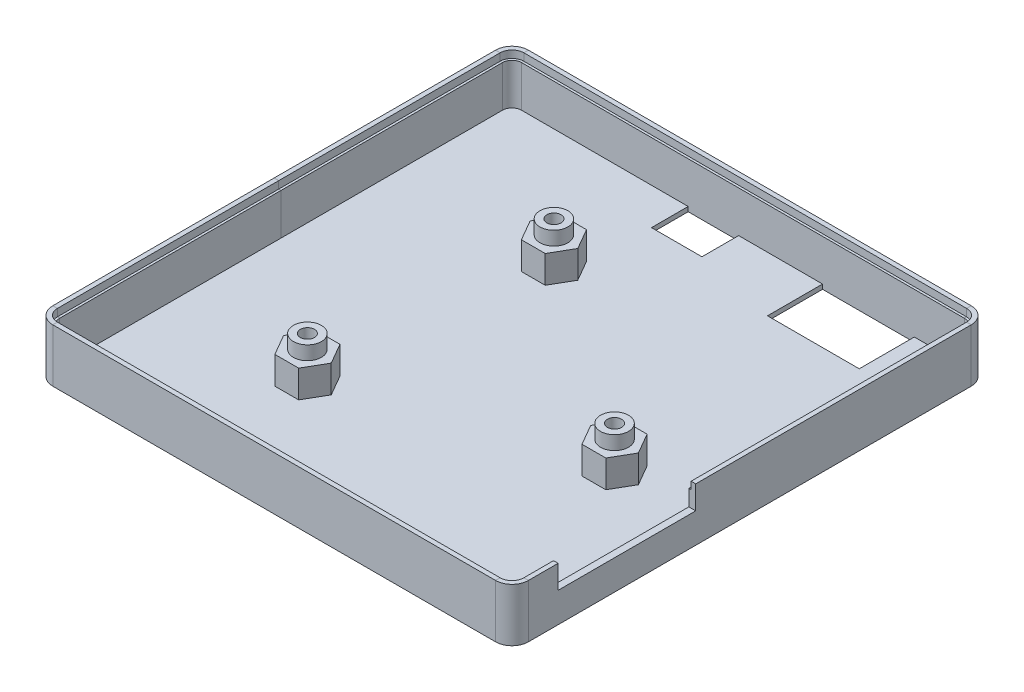
from build123d import *

# Parameters (mm, degrees)
SKETCH5_R           = 1.55
BOSS_EXTRUDE2_DEPTH = 1
BOSS_EXTRUDE3_START = -3
SKETCH6_R           = 1.55
BOSS_EXTRUDE3_DEPTH = 6
SKETCH11_R          = 3.05
SKETCH11_R_2        = 1.55
BOSS_EXTRUDE4_DEPTH = 3
CUT_EXTRUDE1_START  = 2
CUT_EXTRUDE1_DEPTH  = 6
SKETCH8_W           = 11
SKETCH8_H           = 8
SKETCH8_W_2         = 20
SKETCH8_H_2         = 12
CUT_EXTRUDE2_DEPTH  = 2
SKETCH9_W           = 0.45
SKETCH9_H           = 30
CUT_EXTRUDE3_DEPTH  = 3.5
CUT_EXTRUDE4_REACH  = 105.7
SKETCH10_W          = 30
SKETCH10_H          = 5.1


with BuildPart() as part:
    # Sweep1: sweep along a path in Sketch1
    with BuildLine(Plane(origin=(0, 0, 0), x_dir=(1, 0, 0), z_dir=(0, 1, 0))) as sweep1_path:
        Line((-48.26, -50.8), (48.26, -50.8))
        ThreePointArc((48.26, -50.8), (50.056051224, -50.056051224), (50.8, -48.26))
        Line((50.8, -48.26), (50.8, 48.26))
        ThreePointArc((50.8, 48.26), (50.056051224, 50.056051224), (48.26, 50.8))
        Line((48.26, 50.8), (-48.26, 50.8))
        ThreePointArc((-48.26, 50.8), (-50.056051224, 50.056051224), (-50.8, 48.26))
        Line((-50.8, 48.26), (-50.8, -48.26))
        ThreePointArc((-50.8, -48.26), (-50.056051224, -50.056051224), (-48.26, -50.8))
    # Sketch3 → Sweep1 (sweep)
    with BuildSketch(Plane.XY):
        Polygon((-50.85, 1.6), (-51.85, 1.6), (-51.85, -10), (-50.35, -10), (-50.35, 0), (-50.85, 0), align=None)
    sweep(path=sweep1_path.line)

    # Sketch5 → Boss-Extrude2 (add)
    with BuildSketch(Plane.XZ.offset(10)):
        with BuildLine():
            Line((-50.8, 48.26), (-50.8, -48.26))
            ThreePointArc((-50.8, -48.26), (-50.056051224, -50.056051224), (-48.26, -50.8))
            Line((-48.26, -50.8), (48.26, -50.8))
            ThreePointArc((48.26, -50.8), (50.056051224, -50.056051224), (50.8, -48.26))
            Line((50.8, -48.26), (50.8, 48.26))
            ThreePointArc((50.8, 48.26), (50.056051224, 50.056051224), (48.26, 50.8))
            Line((48.26, 50.8), (-48.26, 50.8))
            ThreePointArc((-48.26, 50.8), (-50.056051224, 50.056051224), (-50.8, 48.26))
        make_face()
        with Locations((-15.24, -24.384)):
            Circle(SKETCH5_R, mode=Mode.SUBTRACT)
        with Locations((29.972, 7.62)):
            Circle(SKETCH5_R, mode=Mode.SUBTRACT)
        with Locations((-20.4724, 24.13)):
            Circle(SKETCH5_R, mode=Mode.SUBTRACT)
    extrude(amount=-BOSS_EXTRUDE2_DEPTH)

    # Sketch6 → Boss-Extrude3 (add)
    with BuildSketch(Plane(origin=(0, 0, 0), x_dir=(1, 0, 0), z_dir=(0, 1, 0)).offset(BOSS_EXTRUDE3_START)):
        Polygon((-10.043847577, 24.384), (-12.641923789, 28.884), (-17.838076211, 28.884), (-20.436152423, 24.384), (-17.838076211, 19.884), (-12.641923789, 19.884), align=None)
        with Locations((-15.24, 24.384)):
            Circle(SKETCH6_R, mode=Mode.SUBTRACT)
        Polygon((35.168152423, -7.62), (32.570076211, -3.12), (27.373923789, -3.12), (24.775847577, -7.62), (27.373923789, -12.12), (32.570076211, -12.12), align=None)
        with Locations((29.972, -7.62)):
            Circle(SKETCH6_R, mode=Mode.SUBTRACT)
        Polygon((-15.276247577, -24.13), (-17.874323789, -19.63), (-23.070476211, -19.63), (-25.668552423, -24.13), (-23.070476211, -28.63), (-17.874323789, -28.63), align=None)
        with Locations((-20.4724, -24.13)):
            Circle(SKETCH6_R, mode=Mode.SUBTRACT)
    extrude(amount=-BOSS_EXTRUDE3_DEPTH)

    # Sketch11 → Boss-Extrude4 (add)
    with BuildSketch(Plane(origin=(0, -3, 0), x_dir=(1, 0, 0), z_dir=(0, 1, 0))):
        with Locations((-15.24, 24.384)):
            Circle(SKETCH11_R)
        with Locations((-15.24, 24.384)):
            Circle(SKETCH11_R_2, mode=Mode.SUBTRACT)
        with Locations((-20.4724, -24.13)):
            Circle(SKETCH11_R)
        with Locations((-20.4724, -24.13)):
            Circle(SKETCH11_R_2, mode=Mode.SUBTRACT)
        with Locations((29.972, -7.62)):
            Circle(SKETCH11_R)
        with Locations((29.972, -7.62)):
            Circle(SKETCH11_R_2, mode=Mode.SUBTRACT)
    extrude(amount=BOSS_EXTRUDE4_DEPTH)

    # Sketch7 → Cut-Extrude1 (cut, through all)
    with BuildSketch(Plane.XZ.offset(3).offset(CUT_EXTRUDE1_START)):
        Polygon((-17.239238493, 24.13), (-18.855819246, 26.93), (-22.088980754, 26.93), (-23.705561507, 24.13), (-22.088980754, 21.33), (-18.855819246, 21.33), align=None)
        Polygon((33.205161507, 7.62), (31.588580754, 10.42), (28.355419246, 10.42), (26.738838493, 7.62), (28.355419246, 4.82), (31.588580754, 4.82), align=None)
        Polygon((-12.006838493, -24.384), (-13.623419246, -21.584), (-16.856580754, -21.584), (-18.473161507, -24.384), (-16.856580754, -27.184), (-13.623419246, -27.184), align=None)
    extrude(amount=CUT_EXTRUDE1_DEPTH, mode=Mode.SUBTRACT)

    # Sketch8 → Cut-Extrude2 (cut, through all)
    with BuildSketch(Plane(origin=(0, -9, 0), x_dir=(1, 0, 0), z_dir=(0, 1, 0))):
        with Locations((-6.4408, 46.35)):
            Rectangle(SKETCH8_W, SKETCH8_H)
        with BuildLine():
            Line((50.35, -41.35), (50.35, -48.26))
            ThreePointArc((50.35, -48.26), (49.737853173, -49.737853173), (48.26, -50.35))
            Line((48.26, -50.35), (25.8, -50.35))
            Line((25.8, -50.35), (25.8, -41.35))
            Line((25.8, -41.35), (50.35, -41.35))
        make_face()
        with Locations((27.35, 44.35)):
            Rectangle(SKETCH8_W_2, SKETCH8_H_2)
    extrude(amount=-CUT_EXTRUDE2_DEPTH, mode=Mode.SUBTRACT)

    # Sketch9 → Cut-Extrude3 (cut)
    with BuildSketch(Plane(origin=(0, 0, 0), x_dir=(1, 0, 0), z_dir=(0, 1, 0))):
        with Locations((50.575, -26.8)):
            Rectangle(SKETCH9_W, SKETCH9_H)
    extrude(amount=-CUT_EXTRUDE3_DEPTH, mode=Mode.SUBTRACT)

    # Sketch10 → Cut-Extrude4 (cut, up to next)
    with BuildSketch(Plane(origin=(51.85, 0, 0), x_dir=(0, 0, -1), z_dir=(1, 0, 0)), mode=Mode.PRIVATE) as cut_extrude4_sk1:
        with Locations((-26.8, -0.95)):
            Rectangle(SKETCH10_W, SKETCH10_H)
    cut_extrude4_tool1 = extrude(cut_extrude4_sk1.sketch, amount=-CUT_EXTRUDE4_REACH, mode=Mode.PRIVATE) & part.part
    add(cut_extrude4_tool1.solids().sort_by_distance((51.85, -0.95, 26.8))[0], mode=Mode.SUBTRACT)


solid = part.part
